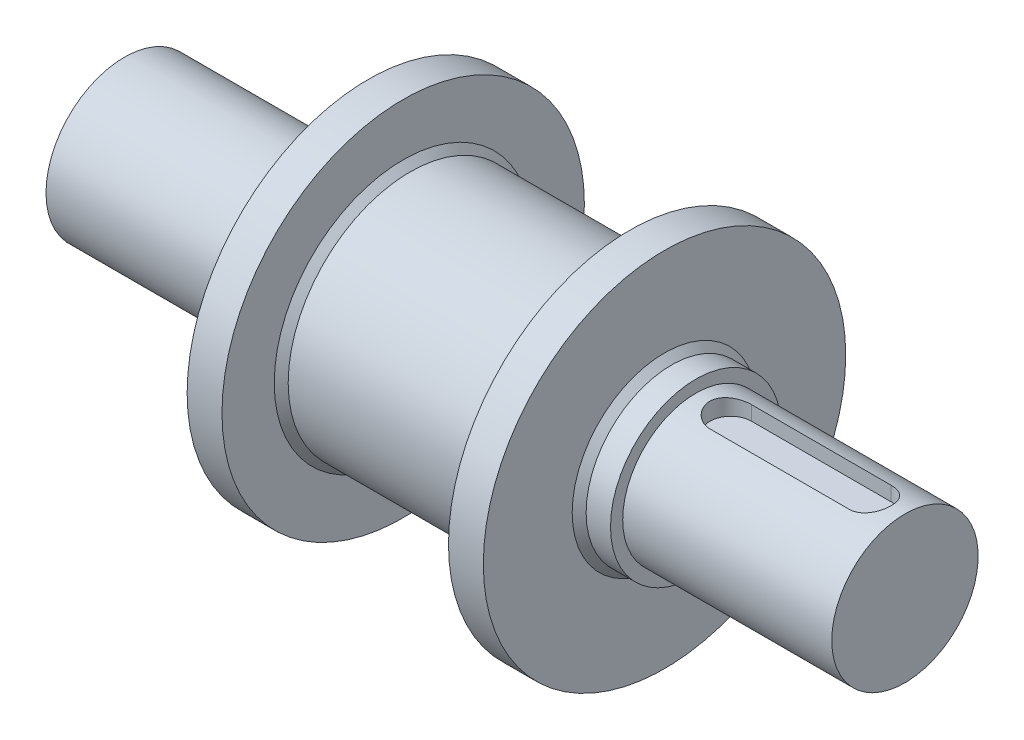
from build123d import *

# Parameters (mm, degrees)
CHAMFER1_SIZE      = 2
CUT_EXTRUDE1_DEPTH = 5


with BuildPart() as part:
    # Sketch1 → Revolve1 (revolve)
    with BuildSketch(Plane.XY):
        Polygon((0, 0), (0, 22.5), (65, 22.5), (65, 27), (70, 27), (70, 52), (80, 52), (80, 35), (145, 35), (145, 52), (155, 52), (155, 24.5), (164, 24.5), (164, 21), (224, 21), (224, 0), align=None)
    revolve(axis=Axis((0, 0, 0), (1, 0, 0)))

    # Chamfer1
    chamfer1_edges = [part.edges().sort_by_distance(p)[0] for p in [
        (155, -24.5, 0),
        (145, -35, 0),
        (80, -35, 0),
    ]]
    chamfer(chamfer1_edges, length=CHAMFER1_SIZE)

    # Sketch2 → Cut-Extrude1 (cut)
    with BuildSketch(Plane(origin=(0, 21, 0), x_dir=(1, 0, 0), z_dir=(0, 1, 0))):
        with BuildLine():
            Line((194, 6), (194, -6))
            Line((194, -6), (174, -6))
            ThreePointArc((174, -6), (168, 0), (174, 6))
            Line((174, 6), (194, 6))
        make_face()
    cut_extrude1 = extrude(amount=-CUT_EXTRUDE1_DEPTH, mode=Mode.SUBTRACT)

    # Mirror1: Cut-Extrude1 across plane
    add(cut_extrude1.mirror(Plane(origin=(194, 16, -6), x_dir=(0, 0, 1), z_dir=(1, 0, 0))), mode=Mode.SUBTRACT)


solid = part.part
